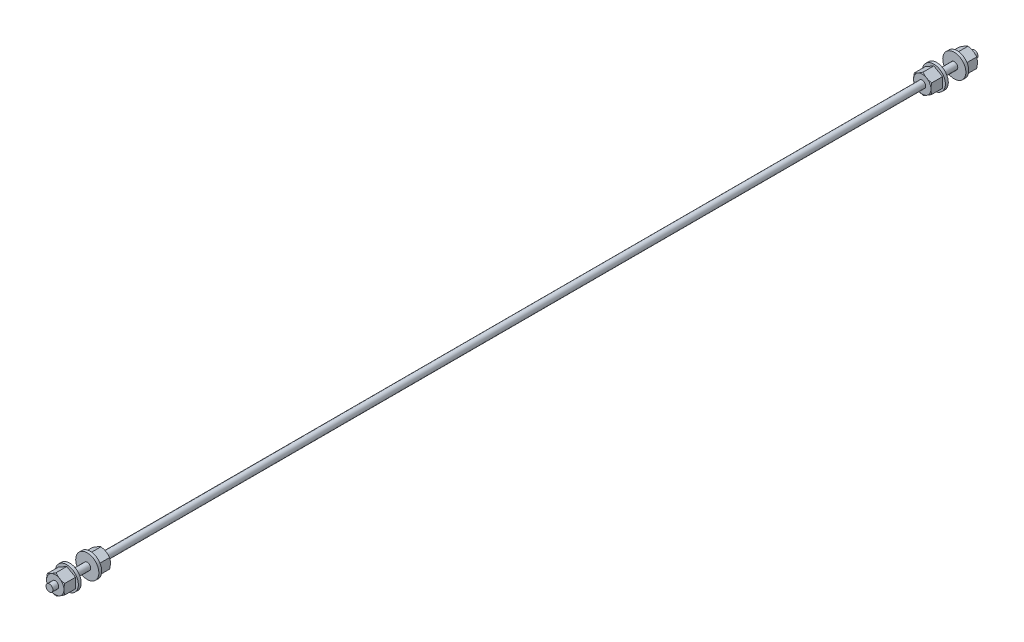
from build123d import *

# Parameters (mm, degrees)
EXTRUDE1_DEPTH          = 7.9375
SKETCH13_R              = 6.35
EXTRUDE3_DEPTH          = 1.5875
SKETCH2_OUTSIDE_W       = 63.61
SKETCH2_OUTSIDE_H       = 63.61
SKETCH2_OUTSIDE_R       = 4.7625
CUT_EXTRUDE1_DEPTH      = 12.985362166
CUT_EXTRUDE1_DRAFT      = -60
SKETCH14_R              = 1.905
BOSS_EXTRUDE1_DEPTH     = 4.826
MIRROR1_COPY_1_SKETCH_W = 63.61
MIRROR1_COPY_1_SKETCH_H = 63.61
MIRROR1_COPY_1_SKETCH_R = 4.7625
MIRROR1_COPY_1_DEPTH    = 12.985362166
MIRROR1_COPY_1_DRAFT    = -60
SKETCH15_R              = 1.905
BOSS_EXTRUDE2_DEPTH     = 225.298
MIRROR2_COPY_1_SKETCH_W = 63.61
MIRROR2_COPY_1_SKETCH_H = 63.61
MIRROR2_COPY_1_SKETCH_R = 4.7625
MIRROR2_COPY_1_DEPTH    = 12.985362166
MIRROR2_COPY_1_DRAFT    = -60
MIRROR2_COPY_2_DEPTH    = 7.9375
MIRROR2_COPY_3_SKETCH_R = 6.35
MIRROR2_COPY_3_DEPTH    = 1.5875
MIRROR2_COPY_4_SKETCH_R = 1.905
MIRROR2_COPY_4_DEPTH    = 4.826
MIRROR2_COPY_5_SKETCH_W = 63.61
MIRROR2_COPY_5_SKETCH_H = 63.61
MIRROR2_COPY_5_SKETCH_R = 4.7625
MIRROR2_COPY_5_DEPTH    = 12.985362166
MIRROR2_COPY_5_DRAFT    = -60
SKETCH16_R              = 1.905
BOSS_EXTRUDE3_DEPTH     = 3.175
SKETCH4_R               = 1.905
BOSS_EXTRUDE4_DEPTH     = 3.175


with BuildPart() as part:
    # Sketch1 → Extrude1 (new body)
    with BuildSketch(Plane.XY):
        Polygon((0, 5.499261314), (-4.7625, 2.749630657), (-4.7625, -2.749630657), (0, -5.499261314), (4.7625, -2.749630657), (4.7625, 2.749630657), align=None)
    extrude1 = extrude(amount=-EXTRUDE1_DEPTH)

    # Sketch13 → Extrude3 (add)
    with BuildSketch(Plane(origin=(0, 0, -7.9375), x_dir=(-1, 0, 0), z_dir=(0, 0, -1))):
        Circle(SKETCH13_R)
    extrude3 = extrude(amount=-EXTRUDE3_DEPTH)


with BuildPart() as cut_extrude1_tool:
    # Sketch2 outside → Cut-Extrude1 (with draft: the straight prism first)
    with BuildSketch(Plane.XY):
        Rectangle(SKETCH2_OUTSIDE_W, SKETCH2_OUTSIDE_H)
        Circle(SKETCH2_OUTSIDE_R, mode=Mode.SUBTRACT)
    extrude(amount=-CUT_EXTRUDE1_DEPTH)
    # Cut-Extrude1: the draft: its side faces are tilted about the plane it starts from
    cut_extrude1_sides = [cut_extrude1_tool.faces().sort_by_distance(p)[0] for p in [
        (0, -31.805, -6.492681083),
        (31.805, 0, -6.492681083),
        (0, 31.805, -6.492681083),
        (-31.805, 0, -6.492681083),
        (-4.7625, 0, -6.492681083),
    ]]
    draft(cut_extrude1_sides, Plane.XY, CUT_EXTRUDE1_DRAFT)


with BuildPart() as part_1:
    add(part.part)

    # Cut-Extrude1: cut by cut_extrude1_tool
    add(cut_extrude1_tool.part, mode=Mode.SUBTRACT)

    # Sketch14 → Boss-Extrude1 (add)
    with BuildSketch(Plane(origin=(0, 0, -7.9375), x_dir=(-1, 0, 0), z_dir=(0, 0, -1))):
        Circle(SKETCH14_R)
    boss_extrude1 = extrude(amount=BOSS_EXTRUDE1_DEPTH)

    # Mirror1: Extrude1, Extrude3, Boss-Extrude1 across plane
    add(extrude1.mirror(Plane(origin=(0, 0, -12.7635), x_dir=(1, 0, 0), z_dir=(0, 0, -1))))
    add(extrude3.mirror(Plane(origin=(0, 0, -12.7635), x_dir=(1, 0, 0), z_dir=(0, 0, -1))))
    add(boss_extrude1.mirror(Plane(origin=(0, 0, -12.7635), x_dir=(1, 0, 0), z_dir=(0, 0, -1))))


with BuildPart() as mirror1_copy_1_tool:
    # Mirror1 copy 1 sketch → Mirror1 copy 1 (with draft: the straight prism first)
    with BuildSketch(Plane(origin=(0, 0, -25.527), x_dir=(1, 0, 0), z_dir=(0, 0, -1))):
        Rectangle(MIRROR1_COPY_1_SKETCH_W, MIRROR1_COPY_1_SKETCH_H)
        Circle(MIRROR1_COPY_1_SKETCH_R, mode=Mode.SUBTRACT)
    extrude(amount=-MIRROR1_COPY_1_DEPTH)
    # Mirror1 copy 1: the draft: its side faces are tilted about the plane it starts from
    mirror1_copy_1_sides = [mirror1_copy_1_tool.faces().sort_by_distance(p)[0] for p in [
        (0, -31.805, -19.034318917),
        (31.805, 0, -19.034318917),
        (0, 31.805, -19.034318917),
        (-31.805, 0, -19.034318917),
        (-4.7625, 0, -19.034318917),
    ]]
    draft(mirror1_copy_1_sides, Plane(origin=(0, 0, -25.527), x_dir=(1, 0, 0), z_dir=(0, 0, -1)), MIRROR1_COPY_1_DRAFT)


with BuildPart() as part_2:
    add(part_1.part)

    # Mirror1 copy 1: cut by mirror1_copy_1_tool
    add(mirror1_copy_1_tool.part, mode=Mode.SUBTRACT)

    # Sketch15 → Boss-Extrude2 (add)
    with BuildSketch(Plane(origin=(0, 0, -25.527), x_dir=(-1, 0, 0), z_dir=(0, 0, -1))):
        Circle(SKETCH15_R)
    boss_extrude2 = extrude(amount=BOSS_EXTRUDE2_DEPTH)

    # Mirror2: Extrude1, Extrude3, Boss-Extrude1, Boss-Extrude2 across plane
    add(extrude1.mirror(Plane(origin=(0, 0, -250.825), x_dir=(1, 0, 0), z_dir=(0, 0, -1))))
    add(extrude3.mirror(Plane(origin=(0, 0, -250.825), x_dir=(1, 0, 0), z_dir=(0, 0, -1))))
    add(boss_extrude1.mirror(Plane(origin=(0, 0, -250.825), x_dir=(1, 0, 0), z_dir=(0, 0, -1))))
    add(boss_extrude2.mirror(Plane(origin=(0, 0, -250.825), x_dir=(1, 0, 0), z_dir=(0, 0, -1))))


with BuildPart() as mirror2_copy_1_tool:
    # Mirror2 copy 1 sketch → Mirror2 copy 1 (with draft: the straight prism first)
    with BuildSketch(Plane(origin=(0, 0, -501.65), x_dir=(1, 0, 0), z_dir=(0, 0, -1))):
        Rectangle(MIRROR2_COPY_1_SKETCH_W, MIRROR2_COPY_1_SKETCH_H)
        Circle(MIRROR2_COPY_1_SKETCH_R, mode=Mode.SUBTRACT)
    extrude(amount=-MIRROR2_COPY_1_DEPTH)
    # Mirror2 copy 1: the draft: its side faces are tilted about the plane it starts from
    mirror2_copy_1_sides = [mirror2_copy_1_tool.faces().sort_by_distance(p)[0] for p in [
        (0, -31.805, -495.157318917),
        (31.805, 0, -495.157318917),
        (0, 31.805, -495.157318917),
        (-31.805, 0, -495.157318917),
        (-4.7625, 0, -495.157318917),
    ]]
    draft(mirror2_copy_1_sides, Plane(origin=(0, 0, -501.65), x_dir=(1, 0, 0), z_dir=(0, 0, -1)), MIRROR2_COPY_1_DRAFT)


with BuildPart() as part_3:
    add(part_2.part)

    # Mirror2 copy 1: cut by mirror2_copy_1_tool
    add(mirror2_copy_1_tool.part, mode=Mode.SUBTRACT)

    # Mirror2 copy 2 sketch → Mirror2 copy 2 (add)
    with BuildSketch(Plane.XY.offset(-476.123)):
        Polygon((0, 5.499261314), (-4.7625, 2.749630657), (-4.7625, -2.749630657), (0, -5.499261314), (4.7625, -2.749630657), (4.7625, 2.749630657), align=None)
    extrude(amount=-MIRROR2_COPY_2_DEPTH)

    # Mirror2 copy 3 sketch → Mirror2 copy 3 (add)
    with BuildSketch(Plane(origin=(0, 0, -484.0605), x_dir=(-1, 0, 0), z_dir=(0, 0, -1))):
        Circle(MIRROR2_COPY_3_SKETCH_R)
    extrude(amount=-MIRROR2_COPY_3_DEPTH)

    # Mirror2 copy 4 sketch → Mirror2 copy 4 (add)
    with BuildSketch(Plane(origin=(0, 0, -484.0605), x_dir=(-1, 0, 0), z_dir=(0, 0, -1))):
        Circle(MIRROR2_COPY_4_SKETCH_R)
    extrude(amount=MIRROR2_COPY_4_DEPTH)


with BuildPart() as mirror2_copy_5_tool:
    # Mirror2 copy 5 sketch → Mirror2 copy 5 (with draft: the straight prism first)
    with BuildSketch(Plane.XY.offset(-476.123)):
        Rectangle(MIRROR2_COPY_5_SKETCH_W, MIRROR2_COPY_5_SKETCH_H)
        Circle(MIRROR2_COPY_5_SKETCH_R, mode=Mode.SUBTRACT)
    extrude(amount=-MIRROR2_COPY_5_DEPTH)
    # Mirror2 copy 5: the draft: its side faces are tilted about the plane it starts from
    mirror2_copy_5_sides = [mirror2_copy_5_tool.faces().sort_by_distance(p)[0] for p in [
        (0, -31.805, -482.615681083),
        (31.805, 0, -482.615681083),
        (0, 31.805, -482.615681083),
        (-31.805, 0, -482.615681083),
        (-4.7625, 0, -482.615681083),
    ]]
    draft(mirror2_copy_5_sides, Plane.XY.offset(-476.123), MIRROR2_COPY_5_DRAFT)


with BuildPart() as part_4:
    add(part_3.part)

    # Mirror2 copy 5: cut by mirror2_copy_5_tool
    add(mirror2_copy_5_tool.part, mode=Mode.SUBTRACT)

    # Sketch16 → Boss-Extrude3 (add)
    with BuildSketch(Plane(origin=(0, 0, -501.65), x_dir=(-1, 0, 0), z_dir=(0, 0, -1))):
        Circle(SKETCH16_R)
    extrude(amount=BOSS_EXTRUDE3_DEPTH)

    # Sketch4 → Boss-Extrude4 (add)
    with BuildSketch(Plane.XY):
        with Locations(Location((0, 0, 0), (0, 0, 180))):
            Circle(SKETCH4_R)
    extrude(amount=BOSS_EXTRUDE4_DEPTH)


solid = part_4.part
